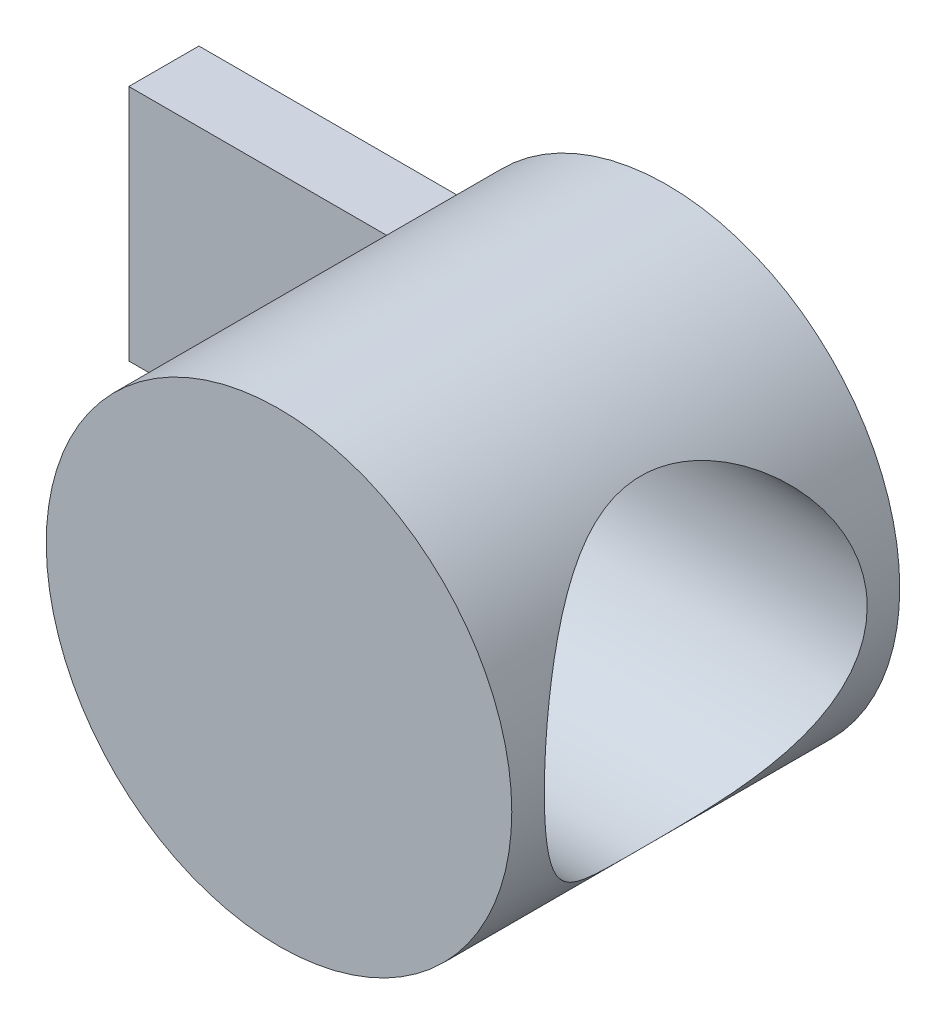
from build123d import *

# Parameters (mm, degrees)
SKETCH_1_R               = 9.3
EXTRUDE_1_DEPTH          = 15.5
SKETCH_2_W               = 10.704532534
SKETCH_2_H               = 9.5
EXTRUDE_2_DEPTH          = 2.8
SKETCH_3_R               = 6.45
CUT_EXTRUDE_1_DEPTH      = 10.3
CUT_EXTRUDE_1_DEPTH_BACK = 2
SKETCH_4_R               = 4
CUT_EXTRUDE_2_DEPTH      = 17.7


with BuildPart() as part:
    # Эскиз1 → Бобышка-Вытянуть1 (new body)
    with BuildSketch(Plane.XY):
        Circle(SKETCH_1_R)
    extrude(amount=EXTRUDE_1_DEPTH)

    # Эскиз2 → Бобышка-Вытянуть2 (add)
    with BuildSketch(Plane.XY):
        with Locations((-13.347733733, 0)):
            Rectangle(SKETCH_2_W, SKETCH_2_H)
    extrude(amount=EXTRUDE_2_DEPTH)

    # Эскиз3 → Вырез-Вытянуть1 (cut, two sides)
    with BuildSketch(Plane(origin=(0, 0, 0), x_dir=(0, 0, -1), z_dir=(1, 0, 0))) as cut_extrude_1_sk:
        with Locations((-7.75, 0)):
            Circle(SKETCH_3_R)
    extrude(amount=CUT_EXTRUDE_1_DEPTH, mode=Mode.SUBTRACT)
    extrude(cut_extrude_1_sk.sketch, amount=-CUT_EXTRUDE_1_DEPTH_BACK, mode=Mode.SUBTRACT)

    # Эскиз4 → Вырез-Вытянуть2 (cut, through all)
    with BuildSketch(Plane(origin=(-2, 0, 0), x_dir=(0, 0, -1), z_dir=(1, 0, 0))):
        with Locations((-7.75, 0)):
            Circle(SKETCH_4_R)
    extrude(amount=-CUT_EXTRUDE_2_DEPTH, mode=Mode.SUBTRACT)


solid = part.part
